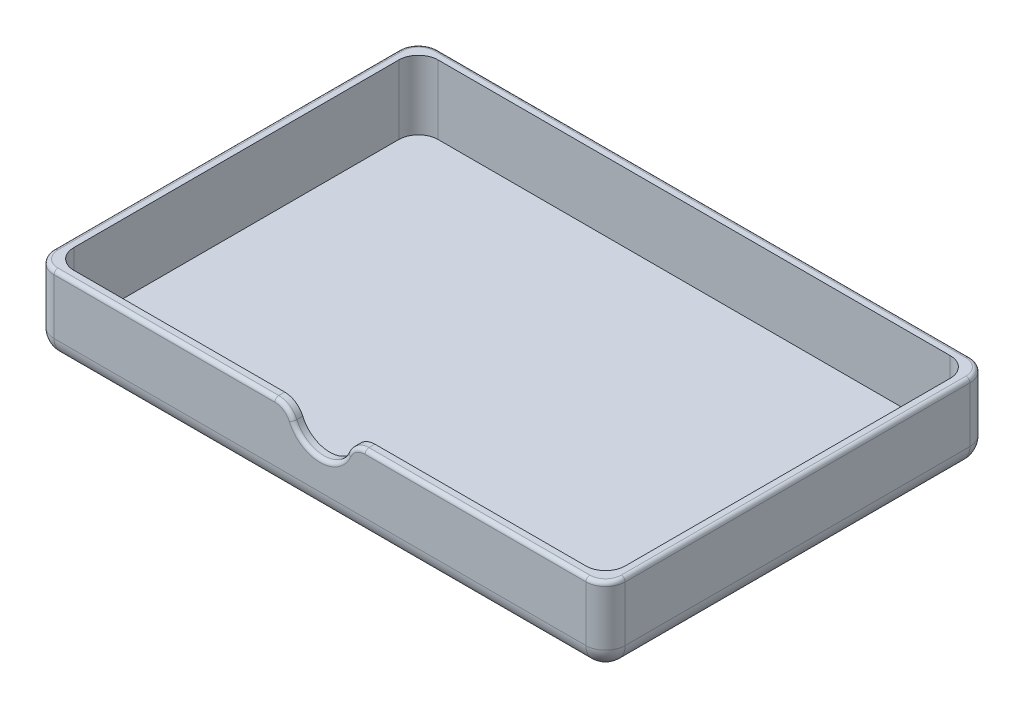
from build123d import *

# Parameters (mm, degrees)
BOSS_EXTRUDE1_DEPTH = 5
BOSS_EXTRUDE2_DEPTH = 185
BOSS_EXTRUDE3_DEPTH = 5
FILLET1_R           = 10
FILLET2_R           = 2


with BuildPart() as part:
    # Sketch1 → Boss-Extrude1 (new body)
    with BuildSketch(Plane.XY):
        with BuildLine():
            Line((-145, 20), (-145, -20))
            Line((-145, -20), (145, -20))
            Line((145, -20), (145, 20))
            Line((145, 20), (15, 20))
            ThreePointArc((15, 20), (0, 5), (-15, 20))
            Line((-15, 20), (-145, 20))
        make_face()
    extrude(amount=-BOSS_EXTRUDE1_DEPTH)

    # Sketch2 → Boss-Extrude2 (add)
    with BuildSketch(Plane(origin=(0, 0, -5), x_dir=(-1, 0, 0), z_dir=(0, 0, -1))):
        Polygon((-140, -15), (-140, 15), (-140, 20), (-145, 20), (-145, -20), (145, -20), (145, 20), (140, 20), (140, 15), (140, -15), align=None)
    extrude(amount=BOSS_EXTRUDE2_DEPTH)

    # Sketch3 → Boss-Extrude3 (add)
    with BuildSketch(Plane(origin=(0, 0, -190), x_dir=(-1, 0, 0), z_dir=(0, 0, -1))):
        with BuildLine():
            Line((140, -15), (140, 20))
            Line((140, 20), (15, 20))
            ThreePointArc((15, 20), (0, 5), (-15, 20))
            Line((-15, 20), (-140, 20))
            Line((-140, 20), (-140, -15))
            Line((-140, -15), (140, -15))
        make_face()
        with BuildLine():
            ThreePointArc((-15, 20), (0, 5), (15, 20))
            Line((15, 20), (-15, 20))
        make_face()
        Polygon((145, 20), (140, 20), (140, -15), (-140, -15), (-140, 20), (-145, 20), (-145, -20), (145, -20), align=None)
    extrude(amount=BOSS_EXTRUDE3_DEPTH)

    # Fillet1
    fillet1_edges = [part.edges().sort_by_distance(p)[0] for p in [
        (145, -20, -97.5),
        (-145, -20, -97.5),
        (-15, 20, -2.5),
        (15, 20, -2.5),
        (-140, 2.5, -190),
        (140, 2.5, -190),
        (-140, 2.5, -5),
        (140, 2.5, -5),
        (145, 0, -195),
        (0, -20, -195),
        (-145, 0, -195),
        (145, 0, 0),
        (0, -20, 0),
        (-145, 0, 0),
    ]]
    fillet(fillet1_edges, radius=FILLET1_R)

    # Fillet2
    fillet2_edges = [part.edges().sort_by_distance(p)[0] for p in [
        (142.071067812, 20, -192.071067812),
        (-142.071067812, 20, -192.071067812),
        (142.071067812, 20, -2.928932188),
        (-142.071067812, 20, -2.928932188),
        (0, 20, -195),
        (-145, 20, -97.5),
        (145, 20, -97.5),
        (78.956439237, 20, 0),
        (0, 5, 0),
        (-78.956439237, 20, 0),
        (-17.4356529, 18.366600265, 0),
        (17.4356529, 18.366600265, 0),
    ]]
    fillet(fillet2_edges, radius=FILLET2_R)


solid = part.part
